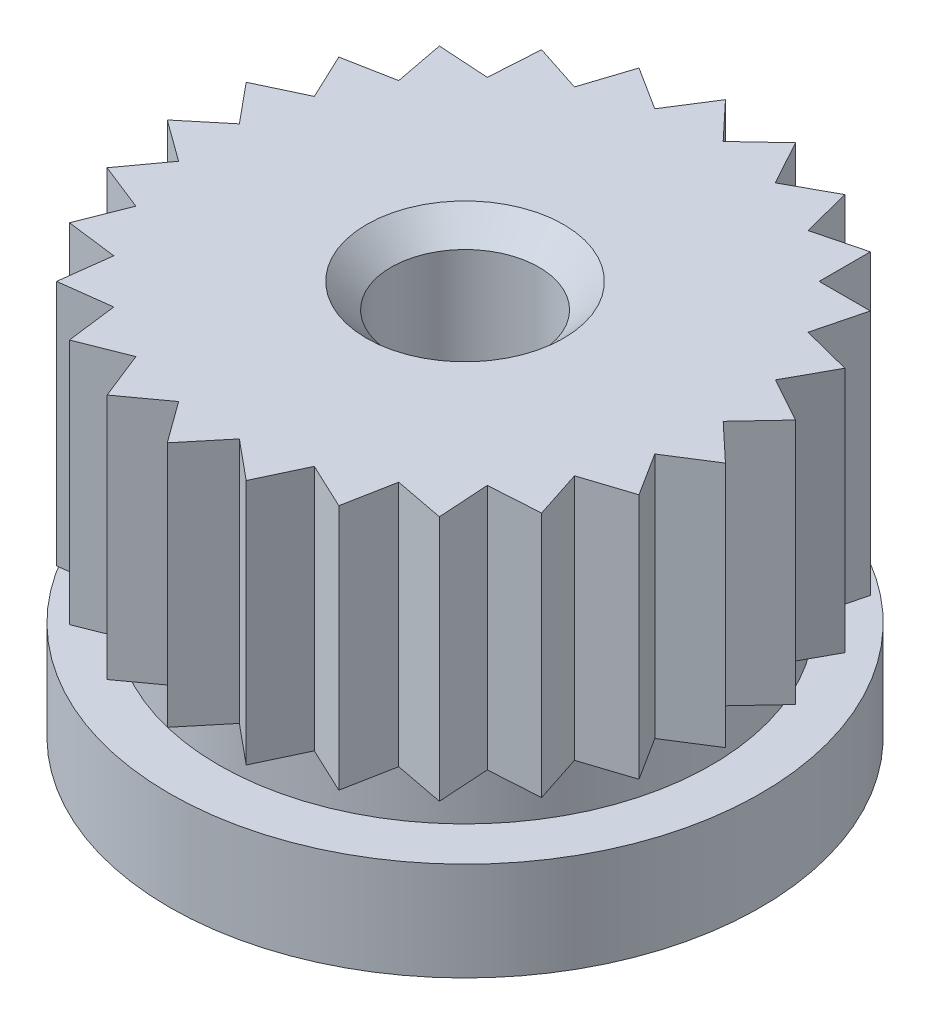
from build123d import *

# Parameters (mm, degrees)
SKETCH1_R                     = 3
BOSS_EXTRUDE1_DEPTH           = 4
SKETCH2_W                     = 0.65
SKETCH2_H                     = 0.65
CUT_EXTRUDE1_DEPTH            = 2.5
CIRPATTERN1_COUNT             = 25
SKETCH3_OUTSIDE_W             = 9.876
SKETCH3_OUTSIDE_H             = 9.876
SKETCH3_OUTSIDE_R             = 2.5
CUT_EXTRUDE2_DEPTH            = 0.5
CSK_FOR_M3_SFHCS1_D           = 1.5
CSK_FOR_M3_SFHCS1_CSINK_D     = 2
CSK_FOR_M3_SFHCS1_CSINK_ANGLE = 90


with BuildPart() as part:
    # Sketch1 → Boss-Extrude1 (new body)
    with BuildSketch(Plane(origin=(0, 0, 0), x_dir=(1, 0, 0), z_dir=(0, 1, 0))):
        Circle(SKETCH1_R)
    extrude(amount=BOSS_EXTRUDE1_DEPTH)

    # Sketch2 → Cut-Extrude1 (cut)
    with BuildSketch(Plane(origin=(0, 4, 0), x_dir=(1, 0, 0), z_dir=(0, 1, 0))):
        with Locations((2.121320344, 2.121320344)):
            Rectangle(SKETCH2_W, SKETCH2_H)
    cut_extrude1 = extrude(amount=-CUT_EXTRUDE1_DEPTH, mode=Mode.SUBTRACT)

    # CirPattern1: Cut-Extrude1 ×25 about axis
    cirpattern1_axis = Axis((0, 4, 0), (0, -1, 0))
    for i in range(1, CIRPATTERN1_COUNT):
        add(cut_extrude1.rotate(cirpattern1_axis, i * 360 / CIRPATTERN1_COUNT), mode=Mode.SUBTRACT)

    # Sketch3 outside → Cut-Extrude2 (cut)
    with BuildSketch(Plane(origin=(0, 1.5, 0), x_dir=(1, 0, 0), z_dir=(0, 1, 0))):
        Rectangle(SKETCH3_OUTSIDE_W, SKETCH3_OUTSIDE_H)
        Circle(SKETCH3_OUTSIDE_R, mode=Mode.SUBTRACT)
    extrude(amount=-CUT_EXTRUDE2_DEPTH, mode=Mode.SUBTRACT)

    # CSK for M3 SFHCS1 (through all)
    with Locations(Plane(origin=(0, 4, 0), x_dir=(1, 0, 0), z_dir=(0, 1, 0))):
        with Locations((0, 0)):
            CounterSinkHole(CSK_FOR_M3_SFHCS1_D / 2, CSK_FOR_M3_SFHCS1_CSINK_D / 2, counter_sink_angle=CSK_FOR_M3_SFHCS1_CSINK_ANGLE)


solid = part.part
